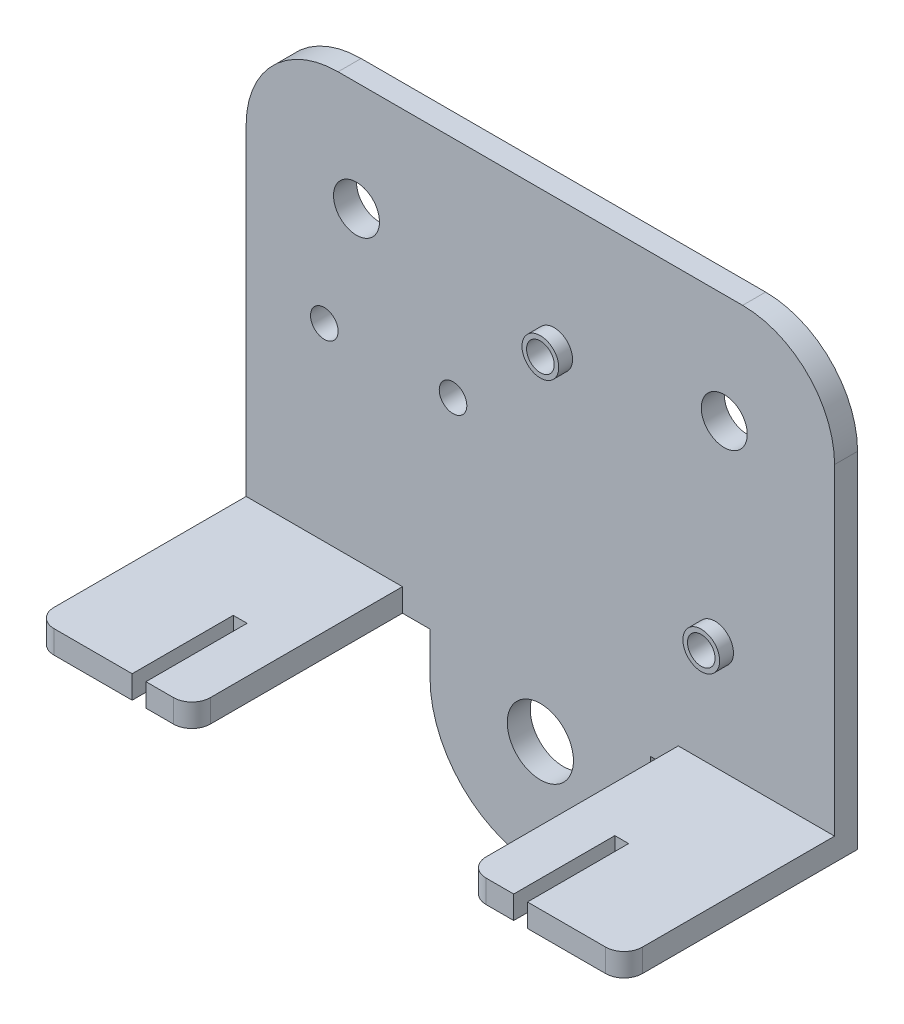
from build123d import *

# Parameters (mm, degrees)
SKETCH1_R           = 3.6
SKETCH1_R_2         = 2.5
SKETCH1_R_3         = 1.5
BOSS_EXTRUDE1_DEPTH = 1.25
SKETCH2_R           = 2
SKETCH2_R_2         = 1.5
BOSS_EXTRUDE2_DEPTH = 1.5
SKETCH3_R           = 2.7
SKETCH3_R_2         = 1.5
BOSS_EXTRUDE3_DEPTH = 4.5
FILLET1_R           = 10
SKETCH4_W           = 17
SKETCH4_H           = 2.5
BOSS_EXTRUDE4_DEPTH = 22.9
SKETCH5_W           = 1.5
SKETCH5_H           = 11
CUT_EXTRUDE1_DEPTH  = 20.1
FILLET2_R           = 2


with BuildPart() as part:
    # Sketch1 → Boss-Extrude1 (new body, symmetric)
    with BuildSketch(Plane.XY):
        with BuildLine():
            Line((-12, -28.35), (-12, -23.75))
            Line((-12, -23.75), (-32, -23.75))
            Line((-32, -23.75), (-32, 23.75))
            Line((-32, 23.75), (32, 23.75))
            Line((32, 23.75), (32, -23.75))
            Line((32, -23.75), (12, -23.75))
            Line((12, -23.75), (12, -28.35))
            ThreePointArc((12, -28.35), (0, -40.35), (-12, -28.35))
        make_face()
        with Locations((0, -28.35)):
            Circle(SKETCH1_R, mode=Mode.SUBTRACT)
        with Locations((-20, 11.85)):
            Circle(SKETCH1_R_2, mode=Mode.SUBTRACT)
        with Locations((19, -9.5)):
            Circle(SKETCH1_R_3, mode=Mode.SUBTRACT)
        with Locations((1.5, 9.4)):
            Circle(SKETCH1_R_3, mode=Mode.SUBTRACT)
        with Locations((20, 11.85)):
            Circle(SKETCH1_R_2, mode=Mode.SUBTRACT)
        with Locations((-23.5, -0.7)):
            Circle(SKETCH1_R_3, mode=Mode.SUBTRACT)
        with Locations((-9.5, -0.7)):
            Circle(SKETCH1_R_3, mode=Mode.SUBTRACT)
    extrude(amount=BOSS_EXTRUDE1_DEPTH, both=True)

    # Sketch2 → Boss-Extrude2 (add)
    with BuildSketch(Plane.XY.offset(1.25)):
        with Locations((19, -9.5)):
            Circle(SKETCH2_R)
        with Locations((19, -9.5)):
            Circle(SKETCH2_R_2, mode=Mode.SUBTRACT)
        with Locations((1.5, 9.4)):
            Circle(SKETCH2_R)
        with Locations((1.5, 9.4)):
            Circle(SKETCH2_R_2, mode=Mode.SUBTRACT)
    extrude(amount=BOSS_EXTRUDE2_DEPTH)

    # Sketch3 → Boss-Extrude3 (add)
    with BuildSketch(Plane(origin=(0, 0, -1.25), x_dir=(-1, 0, 0), z_dir=(0, 0, -1))):
        with Locations((9.5, -0.7)):
            Circle(SKETCH3_R)
        with Locations((9.5, -0.7)):
            Circle(SKETCH3_R_2, mode=Mode.SUBTRACT)
        with Locations((23.5, -0.7)):
            Circle(SKETCH3_R)
        with Locations((23.5, -0.7)):
            Circle(SKETCH3_R_2, mode=Mode.SUBTRACT)
    extrude(amount=BOSS_EXTRUDE3_DEPTH)

    # Fillet1
    fillet1_edges = [part.edges().sort_by_distance(p)[0] for p in [
        (-32, 23.75, 0),
        (32, 23.75, 0),
    ]]
    fillet(fillet1_edges, radius=FILLET1_R)

    # Sketch4 → Boss-Extrude4 (add)
    with BuildSketch(Plane.XY.offset(1.25)):
        with Locations((-23.5, -22.5)):
            Rectangle(SKETCH4_W, SKETCH4_H)
        with Locations((23.5, -22.5)):
            Rectangle(SKETCH4_W, SKETCH4_H)
    extrude(amount=BOSS_EXTRUDE4_DEPTH)

    # Sketch5 → Cut-Extrude1 (cut, through all)
    with BuildSketch(Plane(origin=(0, -21.25, 0), x_dir=(1, 0, 0), z_dir=(0, 1, 0))):
        with Locations((-20.75, -18.65)):
            Rectangle(SKETCH5_W, SKETCH5_H)
        with Locations((20.75, -18.65)):
            Rectangle(SKETCH5_W, SKETCH5_H)
    extrude(amount=-CUT_EXTRUDE1_DEPTH, mode=Mode.SUBTRACT)

    # Fillet2
    fillet2_edges = [part.edges().sort_by_distance(p)[0] for p in [
        (32, -22.5, 24.15),
        (15, -22.5, 24.15),
        (-32, -22.5, 24.15),
        (-15, -22.5, 24.15),
    ]]
    fillet(fillet2_edges, radius=FILLET2_R)


solid = part.part
